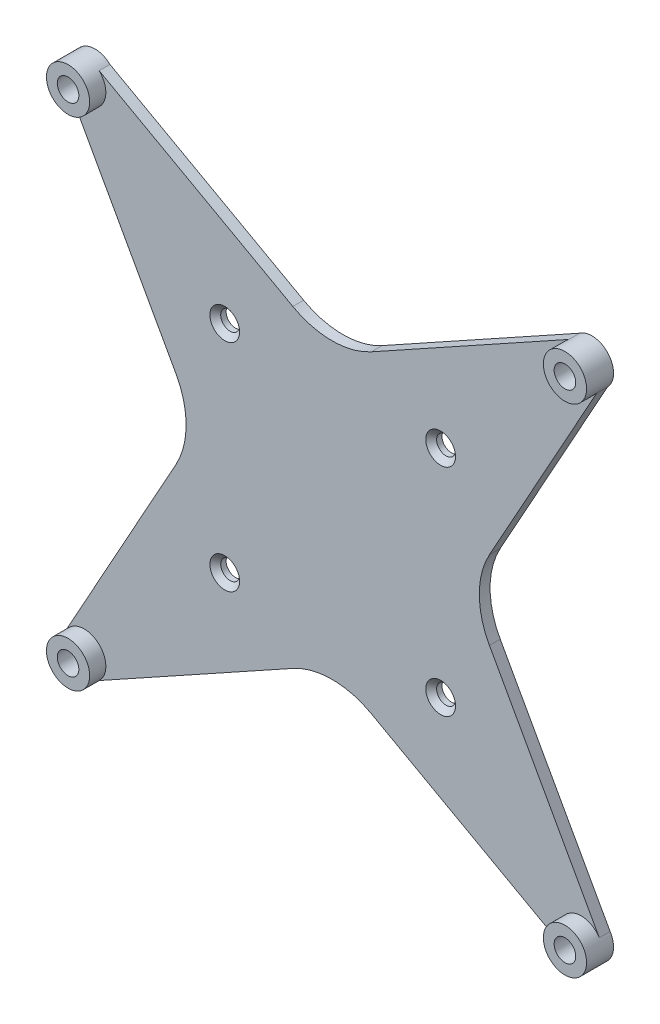
from build123d import *

# Parameters (mm, degrees)
SKETCH2_R             = 4
SKETCH2_R_2           = 2.00000381
BOSS_EXTRUDE1_DEPTH   = 5
BOSS_EXTRUDE1_2_DEPTH = 5
BOSS_EXTRUDE1_3_DEPTH = 5
BOSS_EXTRUDE1_4_DEPTH = 5
BOSS_EXTRUDE2_DEPTH   = 2
FILLET1_R             = 15
CUT_EXTRUDE1_REACH    = 4
SKETCH4_R             = 1.75
CHAMFER1_SIZE         = 1


with BuildPart() as part:
    # Sketch2 → Boss-Extrude1 (new body)
    with BuildSketch(Plane(origin=(0, 0, 183.407141652), x_dir=(-1, 0, 0), z_dir=(0, 0, -1))):
        with Locations((-136.154543014, 230.793193515)):
            Circle(SKETCH2_R)
        with Locations((-136.154543014, 230.793193515)):
            Circle(SKETCH2_R_2, mode=Mode.SUBTRACT)
    extrude(amount=BOSS_EXTRUDE1_DEPTH)



with BuildPart() as body_2:
    # Sketch2 → Boss-Extrude1 2 (new body)
    with BuildSketch(Plane(origin=(0, 0, 183.407141652), x_dir=(-1, 0, 0), z_dir=(0, 0, -1))):
        with Locations((-44.154357594, 230.793193515)):
            Circle(SKETCH2_R)
        with Locations((-44.154357594, 230.793193515)):
            Circle(SKETCH2_R_2, mode=Mode.SUBTRACT)
    extrude(amount=BOSS_EXTRUDE1_2_DEPTH)


with BuildPart() as body_3:
    # Sketch2 → Boss-Extrude1 3 (new body)
    with BuildSketch(Plane(origin=(0, 0, 183.407141652), x_dir=(-1, 0, 0), z_dir=(0, 0, -1))):
        with Locations((-44.154357594, 138.793008095)):
            Circle(SKETCH2_R)
        with Locations((-44.154357594, 138.793008095)):
            Circle(SKETCH2_R_2, mode=Mode.SUBTRACT)
    extrude(amount=BOSS_EXTRUDE1_3_DEPTH)


with BuildPart() as body_4:
    # Sketch2 → Boss-Extrude1 4 (new body)
    with BuildSketch(Plane(origin=(0, 0, 183.407141652), x_dir=(-1, 0, 0), z_dir=(0, 0, -1))):
        with Locations((-136.154543014, 138.793008095)):
            Circle(SKETCH2_R)
        with Locations((-136.154543014, 138.793008095)):
            Circle(SKETCH2_R_2, mode=Mode.SUBTRACT)
    extrude(amount=BOSS_EXTRUDE1_4_DEPTH)


with BuildPart() as part_1:
    add(part.part)

    add(body_2.part)  # Boss-Extrude2 merges body 2

    add(body_3.part)  # Boss-Extrude2 merges body 3

    add(body_4.part)  # Boss-Extrude2 merges body 4
    # Sketch3 → Boss-Extrude2 (add)
    with BuildSketch(Plane(origin=(0, 0, 178.407141652), x_dir=(-1, 0, 0), z_dir=(0, 0, -1))):
        with BuildLine():
            Line((-139.007032023, 227.989034737), (-115.141850609, 184.935107777))
            Line((-115.141850609, 184.935107777), (-139.523599689, 140.949268079))
            ThreePointArc((-139.523599689, 140.949268079), (-138.922212365, 135.905101177), (-133.857043766, 135.518638354))
            Line((-133.857043766, 135.518638354), (-90.042023818, 159.8057005))
            Line((-90.042023818, 159.8057005), (-46.919036743, 135.902238439))
            ThreePointArc((-46.919036743, 135.902238439), (-41.612813753, 135.704229226), (-40.785300919, 140.949268079))
            Line((-40.785300919, 140.949268079), (-65.167049999, 184.935107777))
            Line((-65.167049999, 184.935107777), (-41.301868585, 227.989034737))
            ThreePointArc((-41.301868585, 227.989034737), (-41.306554913, 233.602111436), (-46.919036743, 233.683963171))
            Line((-46.919036743, 233.683963171), (-90.042023818, 209.78050111))
            Line((-90.042023818, 209.78050111), (-133.857043766, 234.067563256))
            ThreePointArc((-133.857043766, 234.067563256), (-139.206449083, 233.378898322), (-139.007032023, 227.989034737))
        make_face()
    extrude(amount=-BOSS_EXTRUDE2_DEPTH)

    # Fillet1
    fillet1_edges = [part_1.edges().sort_by_distance(p)[0] for p in [
        (90.042023818, 209.78050111, 179.407141652),
        (65.167049999, 184.935107777, 179.407141652),
        (90.042023818, 159.8057005, 179.407141652),
        (115.141850609, 184.935107777, 179.407141652),
    ]]
    fillet(fillet1_edges, radius=FILLET1_R)

    # Sketch4 → Cut-Extrude1 (cut, up to next)
    with BuildSketch(Plane.XY.offset(180.407141652), mode=Mode.PRIVATE) as cut_extrude1_sk1:
        with Locations((70.167049999, 204.78050111)):
            Circle(SKETCH4_R)
    cut_extrude1_tool1 = extrude(cut_extrude1_sk1.sketch, amount=-CUT_EXTRUDE1_REACH, mode=Mode.PRIVATE) & part_1.part
    add(cut_extrude1_tool1.solids().sort_by_distance((70.16705, 204.780501, 180.407142))[0], mode=Mode.SUBTRACT)
    # Sketch4 → Cut-Extrude1 (cut, up to next)
    with BuildSketch(Plane.XY.offset(180.407141652), mode=Mode.PRIVATE) as cut_extrude1_sk2:
        with Locations((110.141850609, 204.78050111)):
            Circle(SKETCH4_R)
    cut_extrude1_tool2 = extrude(cut_extrude1_sk2.sketch, amount=-CUT_EXTRUDE1_REACH, mode=Mode.PRIVATE) & part_1.part
    add(cut_extrude1_tool2.solids().sort_by_distance((110.141851, 204.780501, 180.407142))[0], mode=Mode.SUBTRACT)
    # Sketch4 → Cut-Extrude1 (cut, up to next)
    with BuildSketch(Plane.XY.offset(180.407141652), mode=Mode.PRIVATE) as cut_extrude1_sk3:
        with Locations((110.141850609, 164.8057005)):
            Circle(SKETCH4_R)
    cut_extrude1_tool3 = extrude(cut_extrude1_sk3.sketch, amount=-CUT_EXTRUDE1_REACH, mode=Mode.PRIVATE) & part_1.part
    add(cut_extrude1_tool3.solids().sort_by_distance((110.141851, 164.805701, 180.407142))[0], mode=Mode.SUBTRACT)
    # Sketch4 → Cut-Extrude1 (cut, up to next)
    with BuildSketch(Plane.XY.offset(180.407141652), mode=Mode.PRIVATE) as cut_extrude1_sk4:
        with Locations((70.167049999, 164.8057005)):
            Circle(SKETCH4_R)
    cut_extrude1_tool4 = extrude(cut_extrude1_sk4.sketch, amount=-CUT_EXTRUDE1_REACH, mode=Mode.PRIVATE) & part_1.part
    add(cut_extrude1_tool4.solids().sort_by_distance((70.16705, 164.805701, 180.407142))[0], mode=Mode.SUBTRACT)

    # Chamfer1
    chamfer1_edges = [part_1.edges().sort_by_distance(p)[0] for p in [
        (68.417049999, 164.8057005, 180.407141652),
        (108.391850609, 164.8057005, 180.407141652),
        (108.391850609, 204.78050111, 180.407141652),
        (68.417049999, 204.78050111, 180.407141652),
    ]]
    chamfer(chamfer1_edges, length=CHAMFER1_SIZE)


solid = part_1.part
